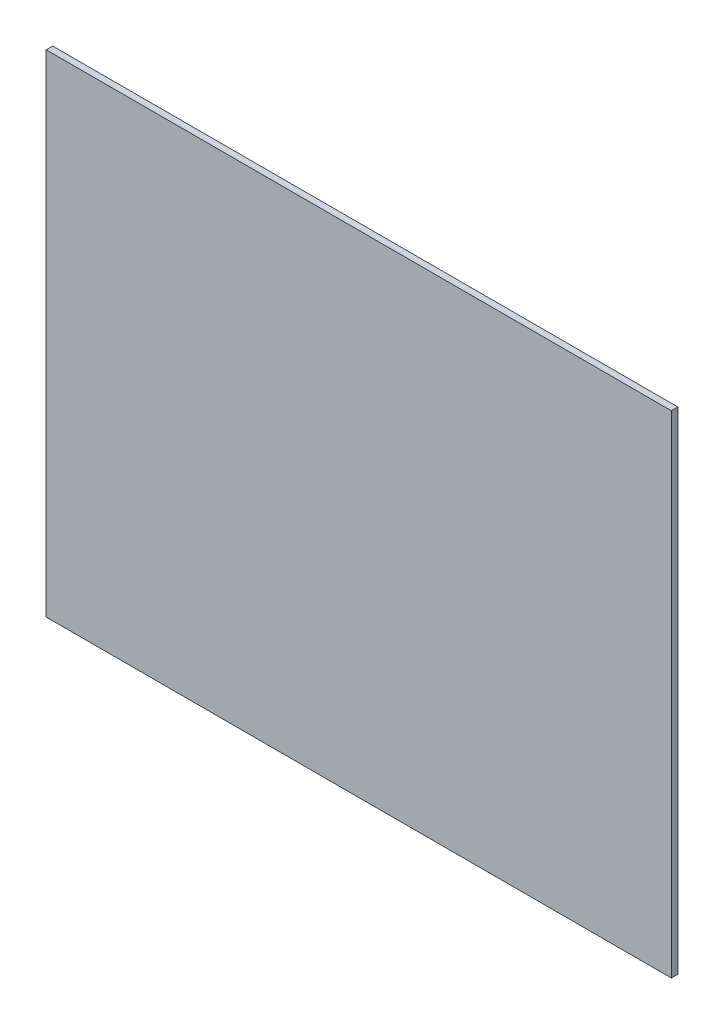
from build123d import *

# Parameters (mm, degrees)
SKETCH1_W           = 304.175
SKETCH1_H           = 239
BOSS_EXTRUDE1_DEPTH = 3.175


with BuildPart() as part:
    # Sketch1 → Boss-Extrude1 (new body)
    with BuildSketch(Plane.XY):
        Rectangle(SKETCH1_W, SKETCH1_H)
    extrude(amount=BOSS_EXTRUDE1_DEPTH)


solid = part.part
